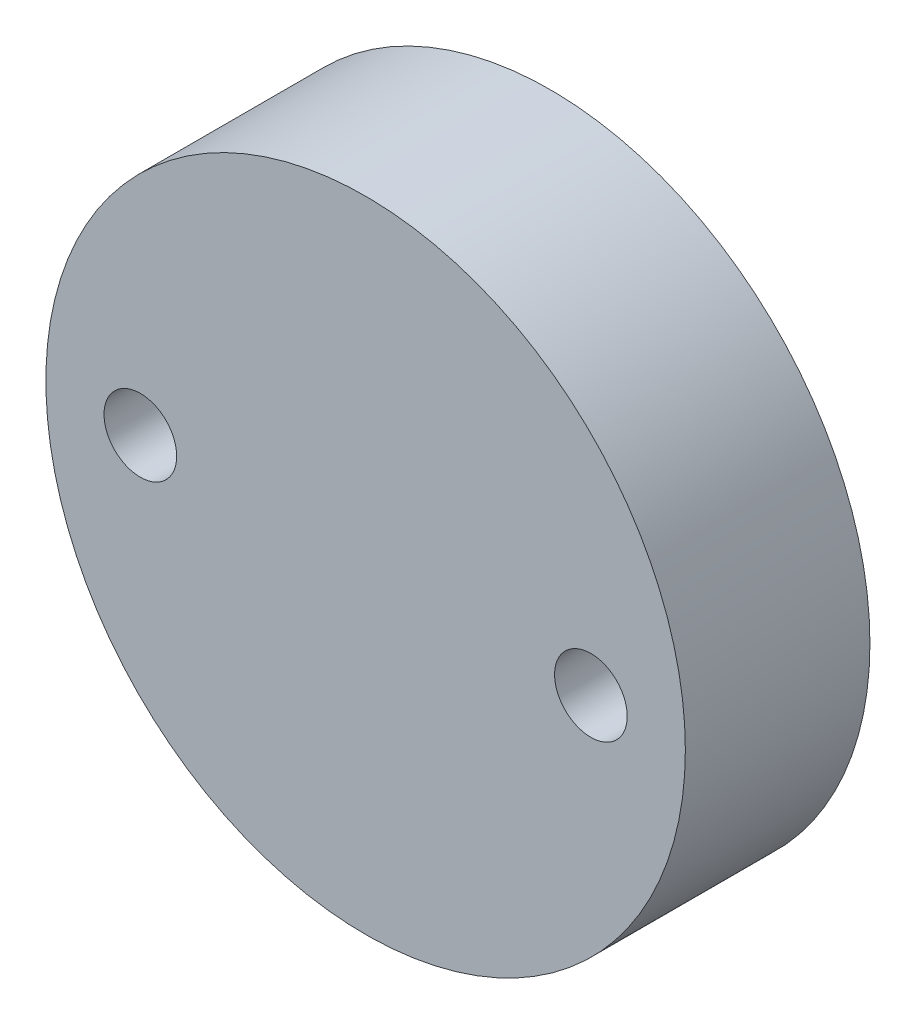
from build123d import *

# Parameters (mm, degrees)
SKETCH1_R           = 11
SKETCH1_R_2         = 1.25
BOSS_EXTRUDE1_DEPTH = 6.35


with BuildPart() as part:
    # Sketch1 → Boss-Extrude1 (new body)
    with BuildSketch(Plane.XY):
        Circle(SKETCH1_R)
        with Locations((-7.75, 0)):
            Circle(SKETCH1_R_2, mode=Mode.SUBTRACT)
        with Locations((7.75, 0)):
            Circle(SKETCH1_R_2, mode=Mode.SUBTRACT)
    extrude(amount=BOSS_EXTRUDE1_DEPTH)


solid = part.part
